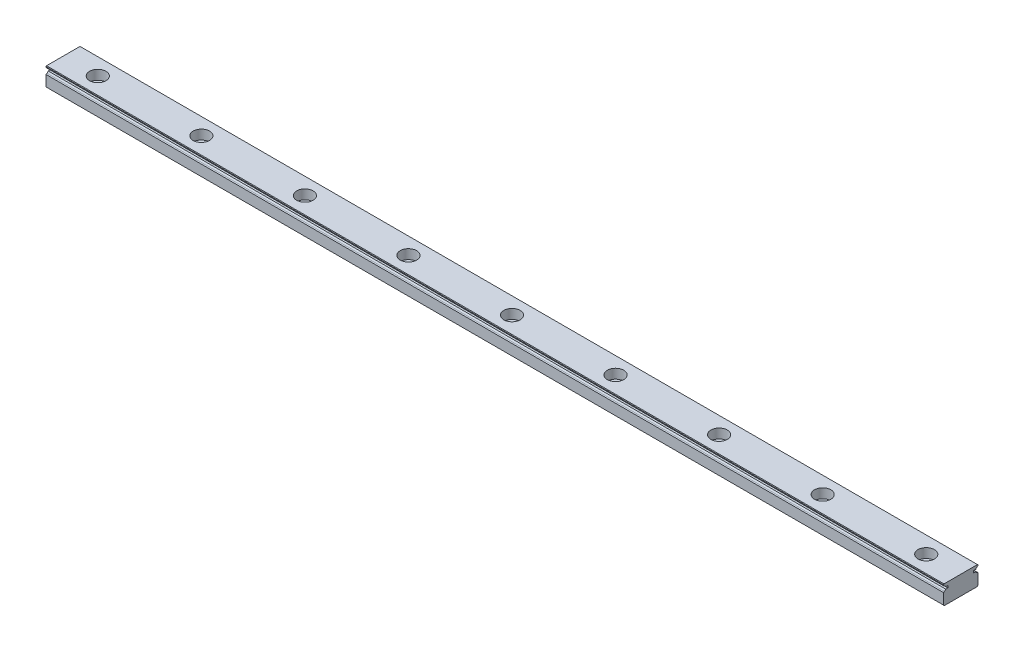
from build123d import *

# Parameters (mm, degrees)
SKETCH1_W                                    = 20
SKETCH1_H                                    = 11
BOSS_EXTRUDE1_DEPTH                          = 520
CUT_EXTRUDE1_DEPTH                           = 521
CBORE_FOR_SOCKET_HEAD_CAP_SCREW1_D           = 6
CBORE_FOR_SOCKET_HEAD_CAP_SCREW1_CBORE_D     = 9.5
CBORE_FOR_SOCKET_HEAD_CAP_SCREW1_CBORE_DEPTH = 5.5
LPATTERN1_COUNT                              = 9
LPATTERN1_PITCH                              = 60
CHAMFER1_SIZE                                = 0.3
CHAMFER2_SIZE                                = 0.5


with BuildPart() as part:
    # Sketch1 → Boss-Extrude1 (new body)
    with BuildSketch(Plane(origin=(-20, 0, 0), x_dir=(0, 0, -1), z_dir=(1, 0, 0))):
        with Locations((0, 5.5)):
            Rectangle(SKETCH1_W, SKETCH1_H)
    extrude(amount=BOSS_EXTRUDE1_DEPTH)

    # Sketch2 → Cut-Extrude1 (cut, through all)
    with BuildSketch(Plane(origin=(-20, 0, 0), x_dir=(0, 0, -1), z_dir=(1, 0, 0))):
        with BuildLine():
            Line((10, 10.221039482), (9.455259378, 9.911421591))
            ThreePointArc((9.455259378, 9.911421591), (9.0228024, 9.564639684), (8.720500078, 9.1))
            Line((8.720500078, 9.1), (7.5, 9.1))
            Line((7.5, 9.1), (7.5, 7.9))
            Line((7.5, 7.9), (8.724976489, 7.9))
            ThreePointArc((8.724976489, 7.9), (9.018551739, 7.450071616), (9.434780564, 7.110401858))
            Line((9.434780564, 7.110401858), (10, 6.778960518))
            Line((10, 6.778960518), (10, 10.221039482))
        make_face()
        with BuildLine():
            Line((-10, 10.221039482), (-10, 6.778960518))
            Line((-10, 6.778960518), (-9.434780564, 7.110401858))
            ThreePointArc((-9.434780564, 7.110401858), (-9.018551739, 7.450071616), (-8.724976489, 7.9))
            Line((-8.724976489, 7.9), (-7.5, 7.9))
            Line((-7.5, 7.9), (-7.5, 9.1))
            Line((-7.5, 9.1), (-8.720500078, 9.1))
            ThreePointArc((-8.720500078, 9.1), (-9.0228024, 9.564639684), (-9.455259378, 9.911421591))
            Line((-9.455259378, 9.911421591), (-10, 10.221039482))
        make_face()
    extrude(amount=CUT_EXTRUDE1_DEPTH, mode=Mode.SUBTRACT)

    # CBORE for Socket Head Cap Screw1 (through all)
    with Locations(Plane(origin=(0, 11, 0), x_dir=(1, 0, 0), z_dir=(0, 1, 0))):
        with Locations((0, 0)):
            cbore_for_socket_head_cap_screw1 = CounterBoreHole(CBORE_FOR_SOCKET_HEAD_CAP_SCREW1_D / 2, CBORE_FOR_SOCKET_HEAD_CAP_SCREW1_CBORE_D / 2, CBORE_FOR_SOCKET_HEAD_CAP_SCREW1_CBORE_DEPTH)

    # LPattern1: CBORE for Socket Head Cap Screw1 ×9
    with Locations(*[(i * LPATTERN1_PITCH, 0, 0) for i in range(1, LPATTERN1_COUNT)]):
        add(cbore_for_socket_head_cap_screw1, mode=Mode.SUBTRACT)

    # Chamfer1
    chamfer1_edges = [part.edges().sort_by_distance(p)[0] for p in [
        (240, 11, 10),
        (240, 11, -10),
    ]]
    chamfer(chamfer1_edges, length=CHAMFER1_SIZE)

    # Chamfer2
    chamfer2_edges = [part.edges().sort_by_distance(p)[0] for p in [
        (240, 0, -10),
        (240, 0, 10),
    ]]
    chamfer(chamfer2_edges, length=CHAMFER2_SIZE)


solid = part.part
